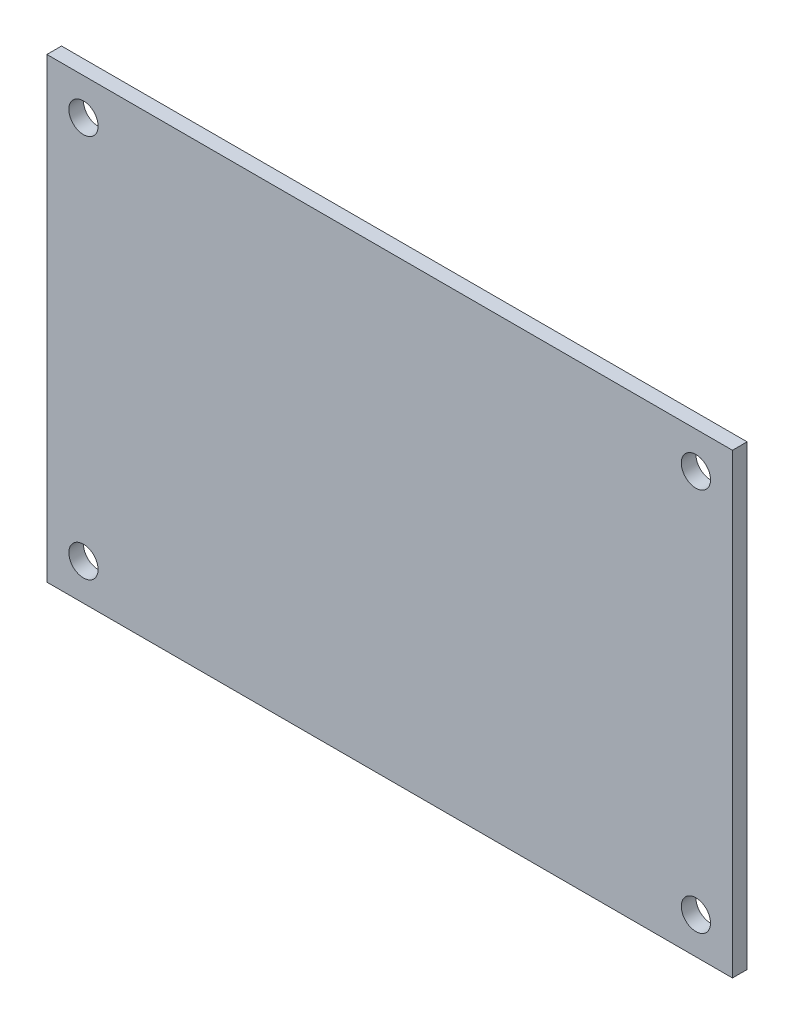
from build123d import *

# Parameters (mm, degrees)
SKETCH1_W           = 75
SKETCH1_H           = 50
BOSS_EXTRUDE1_DEPTH = 1.6
SKETCH2_R           = 1.6
CUT_EXTRUDE1_DEPTH  = 2.6


with BuildPart() as part:
    # Sketch1 → Boss-Extrude1 (new body)
    with BuildSketch(Plane.XY):
        Rectangle(SKETCH1_W, SKETCH1_H)
    extrude(amount=BOSS_EXTRUDE1_DEPTH)

    # Sketch2 → Cut-Extrude1 (cut, through all)
    with BuildSketch(Plane.XY.offset(1.6)):
        with Locations((-33.5, 21)):
            Circle(SKETCH2_R)
        with Locations((33.5, 21)):
            Circle(SKETCH2_R)
        with Locations((33.5, -21)):
            Circle(SKETCH2_R)
        with Locations((-33.5, -21)):
            Circle(SKETCH2_R)
    extrude(amount=-CUT_EXTRUDE1_DEPTH, mode=Mode.SUBTRACT)


solid = part.part
